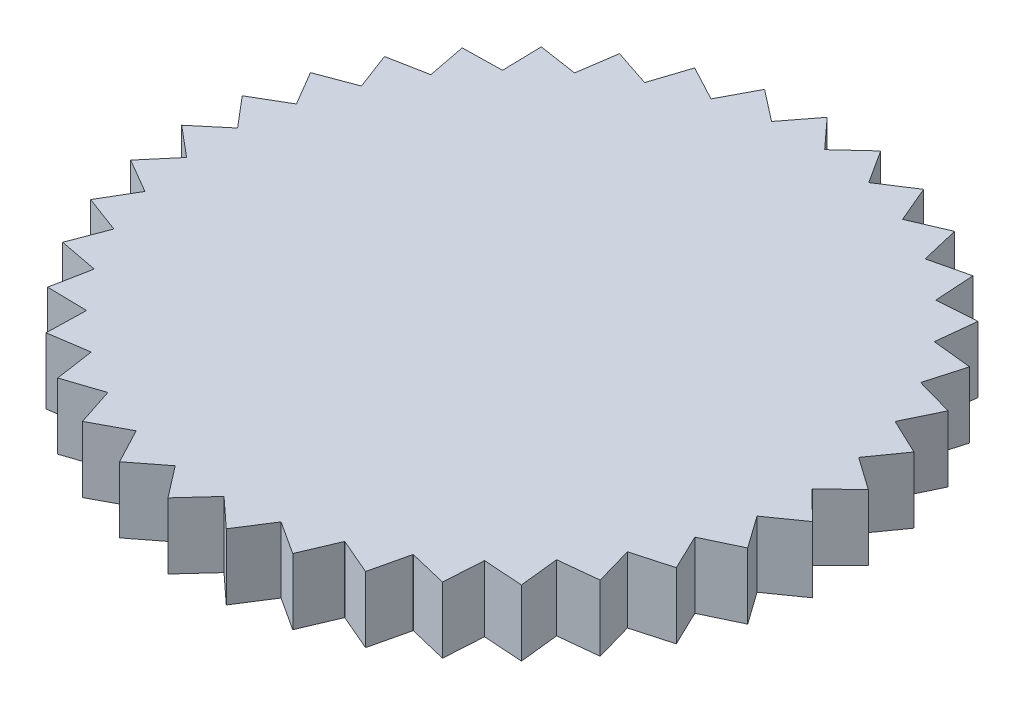
from build123d import *

# Parameters (mm, degrees)
BOSS_EXTRUDE2_DEPTH    = 2
BOSS_EXTRUDE2_2_DEPTH  = 2
BOSS_EXTRUDE2_3_DEPTH  = 2
BOSS_EXTRUDE2_4_DEPTH  = 2
BOSS_EXTRUDE2_5_DEPTH  = 2
BOSS_EXTRUDE2_6_DEPTH  = 2
BOSS_EXTRUDE2_7_DEPTH  = 2
BOSS_EXTRUDE2_8_DEPTH  = 2
BOSS_EXTRUDE2_9_DEPTH  = 2
BOSS_EXTRUDE2_10_DEPTH = 2
BOSS_EXTRUDE2_11_DEPTH = 2
BOSS_EXTRUDE2_12_DEPTH = 2
BOSS_EXTRUDE2_13_DEPTH = 2
BOSS_EXTRUDE2_14_DEPTH = 2
BOSS_EXTRUDE2_15_DEPTH = 2
BOSS_EXTRUDE2_16_DEPTH = 2
BOSS_EXTRUDE2_17_DEPTH = 2
BOSS_EXTRUDE2_18_DEPTH = 2
BOSS_EXTRUDE2_19_DEPTH = 2
BOSS_EXTRUDE2_20_DEPTH = 2
BOSS_EXTRUDE2_21_DEPTH = 2
BOSS_EXTRUDE2_22_DEPTH = 2
BOSS_EXTRUDE2_23_DEPTH = 2
BOSS_EXTRUDE2_24_DEPTH = 2
BOSS_EXTRUDE2_25_DEPTH = 2
BOSS_EXTRUDE2_26_DEPTH = 2
BOSS_EXTRUDE2_27_DEPTH = 2
BOSS_EXTRUDE2_28_DEPTH = 2
BOSS_EXTRUDE2_29_DEPTH = 2
BOSS_EXTRUDE2_30_DEPTH = 2
BOSS_EXTRUDE2_31_DEPTH = 2
BOSS_EXTRUDE2_32_DEPTH = 2
BOSS_EXTRUDE2_33_DEPTH = 2
BOSS_EXTRUDE2_34_DEPTH = 2
BOSS_EXTRUDE2_35_DEPTH = 2
BOSS_EXTRUDE2_36_DEPTH = 2
BOSS_EXTRUDE2_37_DEPTH = 2
BOSS_EXTRUDE3_DEPTH    = 2


with BuildPart() as part:
    # Sketch1 → Boss-Extrude2 (new body)
    with BuildSketch(Plane(origin=(0, 0, 0), x_dir=(1, 0, 0), z_dir=(0, 1, 0))):
        with BuildLine():
            Line((-9.081158193, 0.770999821), (-10, 0))
            Line((-10, 0), (-9.081158193, -0.770999821))
            ThreePointArc((-9.081158193, -0.770999821), (-9.11382877, 0), (-9.081158193, 0.770999821))
        make_face()
    extrude(amount=BOSS_EXTRUDE2_DEPTH)



with BuildPart() as body_2:
    # Sketch1 → Boss-Extrude2 2 (new body)
    with BuildSketch(Plane(origin=(0, 0, 0), x_dir=(1, 0, 0), z_dir=(0, 1, 0))):
        with BuildLine():
            Line((-9.856159103, 1.690008203), (-9.080833602, 0.774813493))
            ThreePointArc((-9.080833602, 0.774813493), (-8.98273464, 1.540244538), (-8.820234397, 2.294632875))
            Line((-8.820234397, 2.294632875), (-9.856159103, 1.690008203))
        make_face()
    extrude(amount=BOSS_EXTRUDE2_2_DEPTH)


with BuildPart() as body_3:
    # Sketch1 → Boss-Extrude2 3 (new body)
    with BuildSketch(Plane(origin=(0, 0, 0), x_dir=(1, 0, 0), z_dir=(0, 1, 0))):
        with BuildLine():
            ThreePointArc((-8.820234397, -2.294632875), (-8.98273464, -1.540244538), (-9.080833602, -0.774813493))
            Line((-9.080833602, -0.774813493), (-9.856159103, -1.690008203))
            Line((-9.856159103, -1.690008203), (-8.820234397, -2.294632875))
        make_face()
    extrude(amount=BOSS_EXTRUDE2_3_DEPTH)


with BuildPart() as body_4:
    # Sketch1 → Boss-Extrude2 4 (new body)
    with BuildSketch(Plane(origin=(0, 0, 0), x_dir=(1, 0, 0), z_dir=(0, 1, 0))):
        with BuildLine():
            Line((-9.428774455, 3.331397947), (-8.819269961, 2.298336834))
            ThreePointArc((-8.819269961, 2.298336834), (-8.593223589, 3.036179046), (-8.305568517, 3.752253518))
            Line((-8.305568517, 3.752253518), (-9.428774455, 3.331397947))
        make_face()
    extrude(amount=BOSS_EXTRUDE2_4_DEPTH)


with BuildPart() as body_5:
    # Sketch1 → Boss-Extrude2 5 (new body)
    with BuildSketch(Plane(origin=(0, 0, 0), x_dir=(1, 0, 0), z_dir=(0, 1, 0))):
        with BuildLine():
            ThreePointArc((-8.305568517, -3.752253518), (-8.593223589, -3.036179046), (-8.819269961, -2.298336834))
            Line((-8.819269961, -2.298336834), (-9.428774455, -3.331397947))
            Line((-9.428774455, -3.331397947), (-8.305568517, -3.752253518))
        make_face()
    extrude(amount=BOSS_EXTRUDE2_5_DEPTH)


with BuildPart() as body_6:
    # Sketch1 → Boss-Extrude2 6 (new body)
    with BuildSketch(Plane(origin=(0, 0, 0), x_dir=(1, 0, 0), z_dir=(0, 1, 0))):
        with BuildLine():
            Line((-8.730141132, 4.876949438), (-8.303991981, 3.755741209))
            ThreePointArc((-8.303991981, 3.755741209), (-7.956501141, 4.44476821), (-7.551966552, 5.10192866))
            Line((-7.551966552, 5.10192866), (-8.730141132, 4.876949438))
        make_face()
    extrude(amount=BOSS_EXTRUDE2_6_DEPTH)


with BuildPart() as body_7:
    # Sketch1 → Boss-Extrude2 7 (new body)
    with BuildSketch(Plane(origin=(0, 0, 0), x_dir=(1, 0, 0), z_dir=(0, 1, 0))):
        with BuildLine():
            ThreePointArc((-7.551966552, -5.10192866), (-7.956501141, -4.44476821), (-8.303991981, -3.755741209))
            Line((-8.303991981, -3.755741209), (-8.730141132, -4.876949438))
            Line((-8.730141132, -4.876949438), (-7.551966552, -5.10192866))
        make_face()
    extrude(amount=BOSS_EXTRUDE2_7_DEPTH)


with BuildPart() as body_8:
    # Sketch1 → Boss-Extrude2 8 (new body)
    with BuildSketch(Plane(origin=(0, 0, 0), x_dir=(1, 0, 0), z_dir=(0, 1, 0))):
        with BuildLine():
            Line((-7.780357543, 6.282199973), (-7.54982327, 5.105099748))
            ThreePointArc((-7.54982327, 5.105099748), (-7.090884642, 5.725489485), (-6.581108259, 6.304830603))
            Line((-6.581108259, 6.304830603), (-7.780357543, 6.282199973))
        make_face()
    extrude(amount=BOSS_EXTRUDE2_8_DEPTH)


with BuildPart() as body_9:
    # Sketch1 → Boss-Extrude2 9 (new body)
    with BuildSketch(Plane(origin=(0, 0, 0), x_dir=(1, 0, 0), z_dir=(0, 1, 0))):
        with BuildLine():
            ThreePointArc((-6.581108259, -6.304830603), (-7.090884642, -5.725489485), (-7.54982327, -5.105099748))
            Line((-7.54982327, -5.105099748), (-7.780357543, -6.282199973))
            Line((-7.780357543, -6.282199973), (-6.581108259, -6.304830603))
        make_face()
    extrude(amount=BOSS_EXTRUDE2_9_DEPTH)


with BuildPart() as body_10:
    # Sketch1 → Boss-Extrude2 10 (new body)
    with BuildSketch(Plane(origin=(0, 0, 0), x_dir=(1, 0, 0), z_dir=(0, 1, 0))):
        with BuildLine():
            Line((-6.606747234, 7.506723053), (-6.57845989, 6.307593861))
            ThreePointArc((-6.57845989, 6.307593861), (-6.021276302, 6.841498853), (-5.420923464, 7.326354049))
            Line((-5.420923464, 7.326354049), (-6.606747234, 7.506723053))
        make_face()
    extrude(amount=BOSS_EXTRUDE2_10_DEPTH)


with BuildPart() as body_11:
    # Sketch1 → Boss-Extrude2 11 (new body)
    with BuildSketch(Plane(origin=(0, 0, 0), x_dir=(1, 0, 0), z_dir=(0, 1, 0))):
        with BuildLine():
            ThreePointArc((-5.420923464, -7.326354049), (-6.021276302, -6.841498853), (-6.57845989, -6.307593861))
            Line((-6.57845989, -6.307593861), (-6.606747234, -7.506723053))
            Line((-6.606747234, -7.506723053), (-5.420923464, -7.326354049))
        make_face()
    extrude(amount=BOSS_EXTRUDE2_11_DEPTH)


with BuildPart() as body_12:
    # Sketch1 → Boss-Extrude2 12 (new body)
    with BuildSketch(Plane(origin=(0, 0, 0), x_dir=(1, 0, 0), z_dir=(0, 1, 0))):
        with BuildLine():
            Line((-5.243072836, 8.515291377), (-5.417846197, 7.328629984))
            ThreePointArc((-5.417846197, 7.328629984), (-4.778446805, 7.760690754), (-4.104788571, 8.137111628))
            Line((-4.104788571, 8.137111628), (-5.243072836, 8.515291377))
        make_face()
    extrude(amount=BOSS_EXTRUDE2_12_DEPTH)


with BuildPart() as body_13:
    # Sketch1 → Boss-Extrude2 13 (new body)
    with BuildSketch(Plane(origin=(0, 0, 0), x_dir=(1, 0, 0), z_dir=(0, 1, 0))):
        with BuildLine():
            ThreePointArc((-4.104788571, -8.137111628), (-4.778446805, -7.760690754), (-5.417846197, -7.328629984))
            Line((-5.417846197, -7.328629984), (-5.243072836, -8.515291377))
            Line((-5.243072836, -8.515291377), (-4.104788571, -8.137111628))
        make_face()
    extrude(amount=BOSS_EXTRUDE2_13_DEPTH)


with BuildPart() as body_14:
    # Sketch1 → Boss-Extrude2 14 (new body)
    with BuildSketch(Plane(origin=(0, 0, 0), x_dir=(1, 0, 0), z_dir=(0, 1, 0))):
        with BuildLine():
            Line((-3.728564778, 9.278890273), (-4.101370932, 8.138834765))
            ThreePointArc((-4.101370932, 8.138834765), (-3.398150094, 8.456621712), (-2.670566384, 8.71377932))
            Line((-2.670566384, 8.71377932), (-3.728564778, 9.278890273))
        make_face()
    extrude(amount=BOSS_EXTRUDE2_14_DEPTH)


with BuildPart() as body_15:
    # Sketch1 → Boss-Extrude2 15 (new body)
    with BuildSketch(Plane(origin=(0, 0, 0), x_dir=(1, 0, 0), z_dir=(0, 1, 0))):
        with BuildLine():
            ThreePointArc((-2.670566384, -8.71377932), (-3.398150094, -8.456621712), (-4.101370932, -8.138834765))
            Line((-4.101370932, -8.138834765), (-3.728564778, -9.278890273))
            Line((-3.728564778, -9.278890273), (-2.670566384, -8.71377932))
        make_face()
    extrude(amount=BOSS_EXTRUDE2_15_DEPTH)


with BuildPart() as body_16:
    # Sketch1 → Boss-Extrude2 16 (new body)
    with BuildSketch(Plane(origin=(0, 0, 0), x_dir=(1, 0, 0), z_dir=(0, 1, 0))):
        with BuildLine():
            Line((-2.1067927, 9.775552389), (-2.666906693, 8.714900088))
            ThreePointArc((-2.666906693, 8.714900088), (-1.920094792, 8.909271061), (-1.159516864, 9.039767447))
            Line((-1.159516864, 9.039767447), (-2.1067927, 9.775552389))
        make_face()
    extrude(amount=BOSS_EXTRUDE2_16_DEPTH)


with BuildPart() as body_17:
    # Sketch1 → Boss-Extrude2 17 (new body)
    with BuildSketch(Plane(origin=(0, 0, 0), x_dir=(1, 0, 0), z_dir=(0, 1, 0))):
        with BuildLine():
            ThreePointArc((-1.159516864, -9.039767447), (-1.920094792, -8.909271061), (-2.666906693, -8.714900088))
            Line((-2.666906693, -8.714900088), (-2.1067927, -9.775552389))
            Line((-2.1067927, -9.775552389), (-1.159516864, -9.039767447))
        make_face()
    extrude(amount=BOSS_EXTRUDE2_17_DEPTH)


with BuildPart() as body_18:
    # Sketch1 → Boss-Extrude2 18 (new body)
    with BuildSketch(Plane(origin=(0, 0, 0), x_dir=(1, 0, 0), z_dir=(0, 1, 0))):
        with BuildLine():
            Line((-0.424412032, 9.990989662), (-1.155720405, 9.040253602))
            ThreePointArc((-1.155720405, 9.040253602), (-0.386801859, 9.105616902), (0.384889844, 9.105697923))
            Line((0.384889844, 9.105697923), (-0.424412032, 9.990989662))
        make_face()
    extrude(amount=BOSS_EXTRUDE2_18_DEPTH)


with BuildPart() as body_19:
    # Sketch1 → Boss-Extrude2 19 (new body)
    with BuildSketch(Plane(origin=(0, 0, 0), x_dir=(1, 0, 0), z_dir=(0, 1, 0))):
        with BuildLine():
            ThreePointArc((0.384889844, -9.105697923), (-0.386801859, -9.105616902), (-1.155720405, -9.040253602))
            Line((-1.155720405, -9.040253602), (-0.424412032, -9.990989662))
            Line((-0.424412032, -9.990989662), (0.384889844, -9.105697923))
        make_face()
    extrude(amount=BOSS_EXTRUDE2_19_DEPTH)


with BuildPart() as body_20:
    # Sketch1 → Boss-Extrude2 20 (new body)
    with BuildSketch(Plane(origin=(0, 0, 0), x_dir=(1, 0, 0), z_dir=(0, 1, 0))):
        with BuildLine():
            Line((1.270178197, 9.919004353), (0.388713856, 9.105535481))
            ThreePointArc((0.388713856, 9.105535481), (1.15761866, 9.040010724), (1.918223973, 8.909674048))
            Line((1.918223973, 8.909674048), (1.270178197, 9.919004353))
        make_face()
    extrude(amount=BOSS_EXTRUDE2_20_DEPTH)


with BuildPart() as body_21:
    # Sketch1 → Boss-Extrude2 21 (new body)
    with BuildSketch(Plane(origin=(0, 0, 0), x_dir=(1, 0, 0), z_dir=(0, 1, 0))):
        with BuildLine():
            ThreePointArc((1.918223973, -8.909674048), (1.15761866, -9.040010724), (0.388713856, -9.105535481))
            Line((0.388713856, -9.105535481), (1.270178197, -9.919004353))
            Line((1.270178197, -9.919004353), (1.918223973, -8.909674048))
        make_face()
    extrude(amount=BOSS_EXTRUDE2_21_DEPTH)


with BuildPart() as body_22:
    # Sketch1 → Boss-Extrude2 22 (new body)
    with BuildSketch(Plane(origin=(0, 0, 0), x_dir=(1, 0, 0), z_dir=(0, 1, 0))):
        with BuildLine():
            Line((2.928227713, 9.561667347), (1.921965527, 8.908867681))
            ThreePointArc((1.921965527, 8.908867681), (2.668736597, 8.714339896), (3.39637429, 8.457335073))
            Line((3.39637429, 8.457335073), (2.928227713, 9.561667347))
        make_face()
    extrude(amount=BOSS_EXTRUDE2_22_DEPTH)


with BuildPart() as body_23:
    # Sketch1 → Boss-Extrude2 23 (new body)
    with BuildSketch(Plane(origin=(0, 0, 0), x_dir=(1, 0, 0), z_dir=(0, 1, 0))):
        with BuildLine():
            ThreePointArc((3.39637429, -8.457335073), (2.668736597, -8.714339896), (1.921965527, -8.908867681))
            Line((1.921965527, -8.908867681), (2.928227713, -9.561667347))
            Line((2.928227713, -9.561667347), (3.39637429, -8.457335073))
        make_face()
    extrude(amount=BOSS_EXTRUDE2_23_DEPTH)


with BuildPart() as body_24:
    # Sketch1 → Boss-Extrude2 24 (new body)
    with BuildSketch(Plane(origin=(0, 0, 0), x_dir=(1, 0, 0), z_dir=(0, 1, 0))):
        with BuildLine():
            Line((4.502037448, 8.929258581), (3.399925749, 8.455907979))
            ThreePointArc((3.399925749, 8.455907979), (4.103079842, 8.137973376), (4.776817103, 7.761693966))
            Line((4.776817103, 7.761693966), (4.502037448, 8.929258581))
        make_face()
    extrude(amount=BOSS_EXTRUDE2_24_DEPTH)


with BuildPart() as body_25:
    # Sketch1 → Boss-Extrude2 25 (new body)
    with BuildSketch(Plane(origin=(0, 0, 0), x_dir=(1, 0, 0), z_dir=(0, 1, 0))):
        with BuildLine():
            ThreePointArc((4.776817103, -7.761693966), (4.103079842, -8.137973376), (3.399925749, -8.455907979))
            Line((3.399925749, -8.455907979), (4.502037448, -8.929258581))
            Line((4.502037448, -8.929258581), (4.776817103, -7.761693966))
        make_face()
    extrude(amount=BOSS_EXTRUDE2_25_DEPTH)


with BuildPart() as body_26:
    # Sketch1 → Boss-Extrude2 26 (new body)
    with BuildSketch(Plane(origin=(0, 0, 0), x_dir=(1, 0, 0), z_dir=(0, 1, 0))):
        with BuildLine():
            Line((5.946331763, 8.039971304), (4.780076297, 7.7596872))
            ThreePointArc((4.780076297, 7.7596872), (5.41938495, 7.327492178), (6.019839585, 6.842763055))
            Line((6.019839585, 6.842763055), (5.946331763, 8.039971304))
        make_face()
    extrude(amount=BOSS_EXTRUDE2_26_DEPTH)


with BuildPart() as body_27:
    # Sketch1 → Boss-Extrude2 27 (new body)
    with BuildSketch(Plane(origin=(0, 0, 0), x_dir=(1, 0, 0), z_dir=(0, 1, 0))):
        with BuildLine():
            ThreePointArc((6.019839585, -6.842763055), (5.41938495, -7.327492178), (4.780076297, -7.7596872))
            Line((4.780076297, -7.7596872), (5.946331763, -8.039971304))
            Line((5.946331763, -8.039971304), (6.019839585, -6.842763055))
        make_face()
    extrude(amount=BOSS_EXTRUDE2_27_DEPTH)


with BuildPart() as body_28:
    # Sketch1 → Boss-Extrude2 28 (new body)
    with BuildSketch(Plane(origin=(0, 0, 0), x_dir=(1, 0, 0), z_dir=(0, 1, 0))):
        with BuildLine():
            Line((7.21956094, 6.91938869), (6.022712753, 6.840234349))
            ThreePointArc((6.022712753, 6.840234349), (6.57978422, 6.306212371), (7.089682242, 5.72697831))
            Line((7.089682242, 5.72697831), (7.21956094, 6.91938869))
        make_face()
    extrude(amount=BOSS_EXTRUDE2_28_DEPTH)


with BuildPart() as body_29:
    # Sketch1 → Boss-Extrude2 29 (new body)
    with BuildSketch(Plane(origin=(0, 0, 0), x_dir=(1, 0, 0), z_dir=(0, 1, 0))):
        with BuildLine():
            ThreePointArc((7.089682242, -5.72697831), (6.57978422, -6.306212371), (6.022712753, -6.840234349))
            Line((6.022712753, -6.840234349), (7.21956094, -6.91938869))
            Line((7.21956094, -6.91938869), (7.089682242, -5.72697831))
        make_face()
    extrude(amount=BOSS_EXTRUDE2_29_DEPTH)


with BuildPart() as body_30:
    # Sketch1 → Boss-Extrude2 30 (new body)
    with BuildSketch(Plane(origin=(0, 0, 0), x_dir=(1, 0, 0), z_dir=(0, 1, 0))):
        with BuildLine():
            Line((8.285096492, 5.599747861), (7.092086729, 5.724000409))
            ThreePointArc((7.092086729, 5.724000409), (7.550895078, 5.103514316), (7.955567649, 4.446438825))
            Line((7.955567649, 4.446438825), (8.285096492, 5.599747861))
        make_face()
    extrude(amount=BOSS_EXTRUDE2_30_DEPTH)


with BuildPart() as body_31:
    # Sketch1 → Boss-Extrude2 31 (new body)
    with BuildSketch(Plane(origin=(0, 0, 0), x_dir=(1, 0, 0), z_dir=(0, 1, 0))):
        with BuildLine():
            ThreePointArc((7.955567649, -4.446438825), (7.550895078, -5.103514316), (7.092086729, -5.724000409))
            Line((7.092086729, -5.724000409), (8.285096492, -5.599747861))
            Line((8.285096492, -5.599747861), (7.955567649, -4.446438825))
        make_face()
    extrude(amount=BOSS_EXTRUDE2_31_DEPTH)


with BuildPart() as body_32:
    # Sketch1 → Boss-Extrude2 32 (new body)
    with BuildSketch(Plane(origin=(0, 0, 0), x_dir=(1, 0, 0), z_dir=(0, 1, 0))):
        with BuildLine():
            Line((9.112284904, 4.119012482), (7.957434282, 4.443097399))
            ThreePointArc((7.957434282, 4.443097399), (8.304780432, 3.753997447), (8.59258586, 3.037983392))
            Line((8.59258586, 3.037983392), (9.112284904, 4.119012482))
        make_face()
    extrude(amount=BOSS_EXTRUDE2_32_DEPTH)


with BuildPart() as body_33:
    # Sketch1 → Boss-Extrude2 33 (new body)
    with BuildSketch(Plane(origin=(0, 0, 0), x_dir=(1, 0, 0), z_dir=(0, 1, 0))):
        with BuildLine():
            ThreePointArc((8.59258586, -3.037983392), (8.304780432, -3.753997447), (7.957434282, -4.443097399))
            Line((7.957434282, -4.443097399), (9.112284904, -4.119012482))
            Line((9.112284904, -4.119012482), (8.59258586, -3.037983392))
        make_face()
    extrude(amount=BOSS_EXTRUDE2_33_DEPTH)


with BuildPart() as body_34:
    # Sketch1 → Boss-Extrude2 34 (new body)
    with BuildSketch(Plane(origin=(0, 0, 0), x_dir=(1, 0, 0), z_dir=(0, 1, 0))):
        with BuildLine():
            Line((9.677329469, 2.519780614), (8.593860939, 3.034374566))
            ThreePointArc((8.593860939, 3.034374566), (8.819752374, 2.296484905), (8.98241102, 1.542130707))
            Line((8.98241102, 1.542130707), (9.677329469, 2.519780614))
        make_face()
    extrude(amount=BOSS_EXTRUDE2_34_DEPTH)


with BuildPart() as body_35:
    # Sketch1 → Boss-Extrude2 35 (new body)
    with BuildSketch(Plane(origin=(0, 0, 0), x_dir=(1, 0, 0), z_dir=(0, 1, 0))):
        with BuildLine():
            ThreePointArc((8.98241102, -1.542130707), (8.819752374, -2.296484905), (8.593860939, -3.034374566))
            Line((8.593860939, -3.034374566), (9.677329469, -2.519780614))
            Line((9.677329469, -2.519780614), (8.98241102, -1.542130707))
        make_face()
    extrude(amount=BOSS_EXTRUDE2_35_DEPTH)


with BuildPart() as body_36:
    # Sketch1 → Boss-Extrude2 36 (new body)
    with BuildSketch(Plane(origin=(0, 0, 0), x_dir=(1, 0, 0), z_dir=(0, 1, 0))):
        with BuildLine():
            Line((9.963974885, 0.848059245), (8.983057864, 1.538358302))
            ThreePointArc((8.983057864, 1.538358302), (9.080996098, 0.772906674), (9.113828569, 0.00191373))
            Line((9.113828569, 0.00191373), (9.963974885, 0.848059245))
        make_face()
    extrude(amount=BOSS_EXTRUDE2_36_DEPTH)


with BuildPart() as body_37:
    # Sketch1 → Boss-Extrude2 37 (new body)
    with BuildSketch(Plane(origin=(0, 0, 0), x_dir=(1, 0, 0), z_dir=(0, 1, 0))):
        with BuildLine():
            ThreePointArc((9.113828569, -0.00191373), (9.080996098, -0.772906674), (8.983057864, -1.538358302))
            Line((8.983057864, -1.538358302), (9.963974885, -0.848059245))
            Line((9.963974885, -0.848059245), (9.113828569, -0.00191373))
        make_face()
    extrude(amount=BOSS_EXTRUDE2_37_DEPTH)


with BuildPart() as part_1:
    add(part.part)

    add(body_2.part)  # Boss-Extrude3 merges body 2

    add(body_3.part)  # Boss-Extrude3 merges body 3

    add(body_4.part)  # Boss-Extrude3 merges body 4

    add(body_5.part)  # Boss-Extrude3 merges body 5

    add(body_6.part)  # Boss-Extrude3 merges body 6

    add(body_7.part)  # Boss-Extrude3 merges body 7

    add(body_8.part)  # Boss-Extrude3 merges body 8

    add(body_9.part)  # Boss-Extrude3 merges body 9

    add(body_10.part)  # Boss-Extrude3 merges body 10

    add(body_11.part)  # Boss-Extrude3 merges body 11

    add(body_12.part)  # Boss-Extrude3 merges body 12

    add(body_13.part)  # Boss-Extrude3 merges body 13

    add(body_14.part)  # Boss-Extrude3 merges body 14

    add(body_15.part)  # Boss-Extrude3 merges body 15

    add(body_16.part)  # Boss-Extrude3 merges body 16

    add(body_17.part)  # Boss-Extrude3 merges body 17

    add(body_18.part)  # Boss-Extrude3 merges body 18

    add(body_19.part)  # Boss-Extrude3 merges body 19

    add(body_20.part)  # Boss-Extrude3 merges body 20

    add(body_21.part)  # Boss-Extrude3 merges body 21

    add(body_22.part)  # Boss-Extrude3 merges body 22

    add(body_23.part)  # Boss-Extrude3 merges body 23

    add(body_24.part)  # Boss-Extrude3 merges body 24

    add(body_25.part)  # Boss-Extrude3 merges body 25

    add(body_26.part)  # Boss-Extrude3 merges body 26

    add(body_27.part)  # Boss-Extrude3 merges body 27

    add(body_28.part)  # Boss-Extrude3 merges body 28

    add(body_29.part)  # Boss-Extrude3 merges body 29

    add(body_30.part)  # Boss-Extrude3 merges body 30

    add(body_31.part)  # Boss-Extrude3 merges body 31

    add(body_32.part)  # Boss-Extrude3 merges body 32

    add(body_33.part)  # Boss-Extrude3 merges body 33

    add(body_34.part)  # Boss-Extrude3 merges body 34

    add(body_35.part)  # Boss-Extrude3 merges body 35

    add(body_36.part)  # Boss-Extrude3 merges body 36

    add(body_37.part)  # Boss-Extrude3 merges body 37
    # Sketch1_7 → Boss-Extrude3 (add)
    with BuildSketch(Plane(origin=(0, 0, 0), x_dir=(1, 0, 0), z_dir=(0, 1, 0))):
        with BuildLine():
            ThreePointArc((-9.080833602, 0.774813493), (-9.080996098, 0.772906674), (-9.081158193, 0.770999821))
            ThreePointArc((-9.081158193, 0.770999821), (-9.11382877, 0), (-9.081158193, -0.770999821))
            ThreePointArc((-9.081158193, -0.770999821), (-9.080996098, -0.772906674), (-9.080833602, -0.774813493))
            ThreePointArc((-9.080833602, -0.774813493), (-8.98273464, -1.540244538), (-8.820234397, -2.294632875))
            ThreePointArc((-8.820234397, -2.294632875), (-8.819752374, -2.296484905), (-8.819269961, -2.298336834))
            ThreePointArc((-8.819269961, -2.298336834), (-8.593223589, -3.036179046), (-8.305568517, -3.752253518))
            ThreePointArc((-8.305568517, -3.752253518), (-8.304780432, -3.753997447), (-8.303991981, -3.755741209))
            ThreePointArc((-8.303991981, -3.755741209), (-7.956501141, -4.44476821), (-7.551966552, -5.10192866))
            ThreePointArc((-7.551966552, -5.10192866), (-7.550895078, -5.103514316), (-7.54982327, -5.105099748))
            ThreePointArc((-7.54982327, -5.105099748), (-7.090884642, -5.725489485), (-6.581108259, -6.304830603))
            ThreePointArc((-6.581108259, -6.304830603), (-6.57978422, -6.306212371), (-6.57845989, -6.307593861))
            ThreePointArc((-6.57845989, -6.307593861), (-6.021276302, -6.841498853), (-5.420923464, -7.326354049))
            ThreePointArc((-5.420923464, -7.326354049), (-5.41938495, -7.327492178), (-5.417846197, -7.328629984))
            ThreePointArc((-5.417846197, -7.328629984), (-4.778446805, -7.760690754), (-4.104788571, -8.137111628))
            ThreePointArc((-4.104788571, -8.137111628), (-4.103079842, -8.137973376), (-4.101370932, -8.138834765))
            ThreePointArc((-4.101370932, -8.138834765), (-3.398150094, -8.456621712), (-2.670566384, -8.71377932))
            ThreePointArc((-2.670566384, -8.71377932), (-2.668736597, -8.714339896), (-2.666906693, -8.714900088))
            ThreePointArc((-2.666906693, -8.714900088), (-1.920094792, -8.909271061), (-1.159516864, -9.039767447))
            ThreePointArc((-1.159516864, -9.039767447), (-1.15761866, -9.040010724), (-1.155720405, -9.040253602))
            ThreePointArc((-1.155720405, -9.040253602), (-0.386801859, -9.105616902), (0.384889844, -9.105697923))
            ThreePointArc((0.384889844, -9.105697923), (0.386801859, -9.105616902), (0.388713856, -9.105535481))
            ThreePointArc((0.388713856, -9.105535481), (1.15761866, -9.040010724), (1.918223973, -8.909674048))
            ThreePointArc((1.918223973, -8.909674048), (1.920094792, -8.909271061), (1.921965527, -8.908867681))
            ThreePointArc((1.921965527, -8.908867681), (2.668736597, -8.714339896), (3.39637429, -8.457335073))
            ThreePointArc((3.39637429, -8.457335073), (3.398150094, -8.456621712), (3.399925749, -8.455907979))
            ThreePointArc((3.399925749, -8.455907979), (4.103079842, -8.137973376), (4.776817103, -7.761693966))
            ThreePointArc((4.776817103, -7.761693966), (4.778446805, -7.760690754), (4.780076297, -7.7596872))
            ThreePointArc((4.780076297, -7.7596872), (5.41938495, -7.327492178), (6.019839585, -6.842763055))
            ThreePointArc((6.019839585, -6.842763055), (6.021276302, -6.841498853), (6.022712753, -6.840234349))
            ThreePointArc((6.022712753, -6.840234349), (6.57978422, -6.306212371), (7.089682242, -5.72697831))
            ThreePointArc((7.089682242, -5.72697831), (7.090884642, -5.725489485), (7.092086729, -5.724000409))
            ThreePointArc((7.092086729, -5.724000409), (7.550895078, -5.103514316), (7.955567649, -4.446438825))
            ThreePointArc((7.955567649, -4.446438825), (7.956501141, -4.44476821), (7.957434282, -4.443097399))
            ThreePointArc((7.957434282, -4.443097399), (8.304780432, -3.753997447), (8.59258586, -3.037983392))
            ThreePointArc((8.59258586, -3.037983392), (8.593223589, -3.036179046), (8.593860939, -3.034374566))
            ThreePointArc((8.593860939, -3.034374566), (8.819752374, -2.296484905), (8.98241102, -1.542130707))
            ThreePointArc((8.98241102, -1.542130707), (8.98273464, -1.540244538), (8.983057864, -1.538358302))
            ThreePointArc((8.983057864, -1.538358302), (9.080996098, -0.772906674), (9.113828569, -0.00191373))
            ThreePointArc((9.113828569, -0.00191373), (9.11382872, -0.000956865), (9.11382877, 0))
            ThreePointArc((9.11382877, 0), (9.11382872, 0.000956865), (9.113828569, 0.00191373))
            ThreePointArc((9.113828569, 0.00191373), (9.080996098, 0.772906674), (8.983057864, 1.538358302))
            ThreePointArc((8.983057864, 1.538358302), (8.98273464, 1.540244538), (8.98241102, 1.542130707))
            ThreePointArc((8.98241102, 1.542130707), (8.819752374, 2.296484905), (8.593860939, 3.034374566))
            ThreePointArc((8.593860939, 3.034374566), (8.593223589, 3.036179046), (8.59258586, 3.037983392))
            ThreePointArc((8.59258586, 3.037983392), (8.304780432, 3.753997447), (7.957434282, 4.443097399))
            ThreePointArc((7.957434282, 4.443097399), (7.956501141, 4.44476821), (7.955567649, 4.446438825))
            ThreePointArc((7.955567649, 4.446438825), (7.550895078, 5.103514316), (7.092086729, 5.724000409))
            ThreePointArc((7.092086729, 5.724000409), (7.090884642, 5.725489485), (7.089682242, 5.72697831))
            ThreePointArc((7.089682242, 5.72697831), (6.57978422, 6.306212371), (6.022712753, 6.840234349))
            ThreePointArc((6.022712753, 6.840234349), (6.021276302, 6.841498853), (6.019839585, 6.842763055))
            ThreePointArc((6.019839585, 6.842763055), (5.41938495, 7.327492178), (4.780076297, 7.7596872))
            ThreePointArc((4.780076297, 7.7596872), (4.778446805, 7.760690754), (4.776817103, 7.761693966))
            ThreePointArc((4.776817103, 7.761693966), (4.103079842, 8.137973376), (3.399925749, 8.455907979))
            ThreePointArc((3.399925749, 8.455907979), (3.398150094, 8.456621712), (3.39637429, 8.457335073))
            ThreePointArc((3.39637429, 8.457335073), (2.668736597, 8.714339896), (1.921965527, 8.908867681))
            ThreePointArc((1.921965527, 8.908867681), (1.920094792, 8.909271061), (1.918223973, 8.909674048))
            ThreePointArc((1.918223973, 8.909674048), (1.15761866, 9.040010724), (0.388713856, 9.105535481))
            ThreePointArc((0.388713856, 9.105535481), (0.386801859, 9.105616902), (0.384889844, 9.105697923))
            ThreePointArc((0.384889844, 9.105697923), (-0.386801859, 9.105616902), (-1.155720405, 9.040253602))
            ThreePointArc((-1.155720405, 9.040253602), (-1.15761866, 9.040010724), (-1.159516864, 9.039767447))
            ThreePointArc((-1.159516864, 9.039767447), (-1.920094792, 8.909271061), (-2.666906693, 8.714900088))
            ThreePointArc((-2.666906693, 8.714900088), (-2.668736597, 8.714339896), (-2.670566384, 8.71377932))
            ThreePointArc((-2.670566384, 8.71377932), (-3.398150094, 8.456621712), (-4.101370932, 8.138834765))
            ThreePointArc((-4.101370932, 8.138834765), (-4.103079842, 8.137973376), (-4.104788571, 8.137111628))
            ThreePointArc((-4.104788571, 8.137111628), (-4.778446805, 7.760690754), (-5.417846197, 7.328629984))
            ThreePointArc((-5.417846197, 7.328629984), (-5.41938495, 7.327492178), (-5.420923464, 7.326354049))
            ThreePointArc((-5.420923464, 7.326354049), (-6.021276302, 6.841498853), (-6.57845989, 6.307593861))
            ThreePointArc((-6.57845989, 6.307593861), (-6.57978422, 6.306212371), (-6.581108259, 6.304830603))
            ThreePointArc((-6.581108259, 6.304830603), (-7.090884642, 5.725489485), (-7.54982327, 5.105099748))
            ThreePointArc((-7.54982327, 5.105099748), (-7.550895078, 5.103514316), (-7.551966552, 5.10192866))
            ThreePointArc((-7.551966552, 5.10192866), (-7.956501141, 4.44476821), (-8.303991981, 3.755741209))
            ThreePointArc((-8.303991981, 3.755741209), (-8.304780432, 3.753997447), (-8.305568517, 3.752253518))
            ThreePointArc((-8.305568517, 3.752253518), (-8.593223589, 3.036179046), (-8.819269961, 2.298336834))
            ThreePointArc((-8.819269961, 2.298336834), (-8.819752374, 2.296484905), (-8.820234397, 2.294632875))
            ThreePointArc((-8.820234397, 2.294632875), (-8.98273464, 1.540244538), (-9.080833602, 0.774813493))
        make_face()
    extrude(amount=BOSS_EXTRUDE3_DEPTH)


solid = part_1.part
